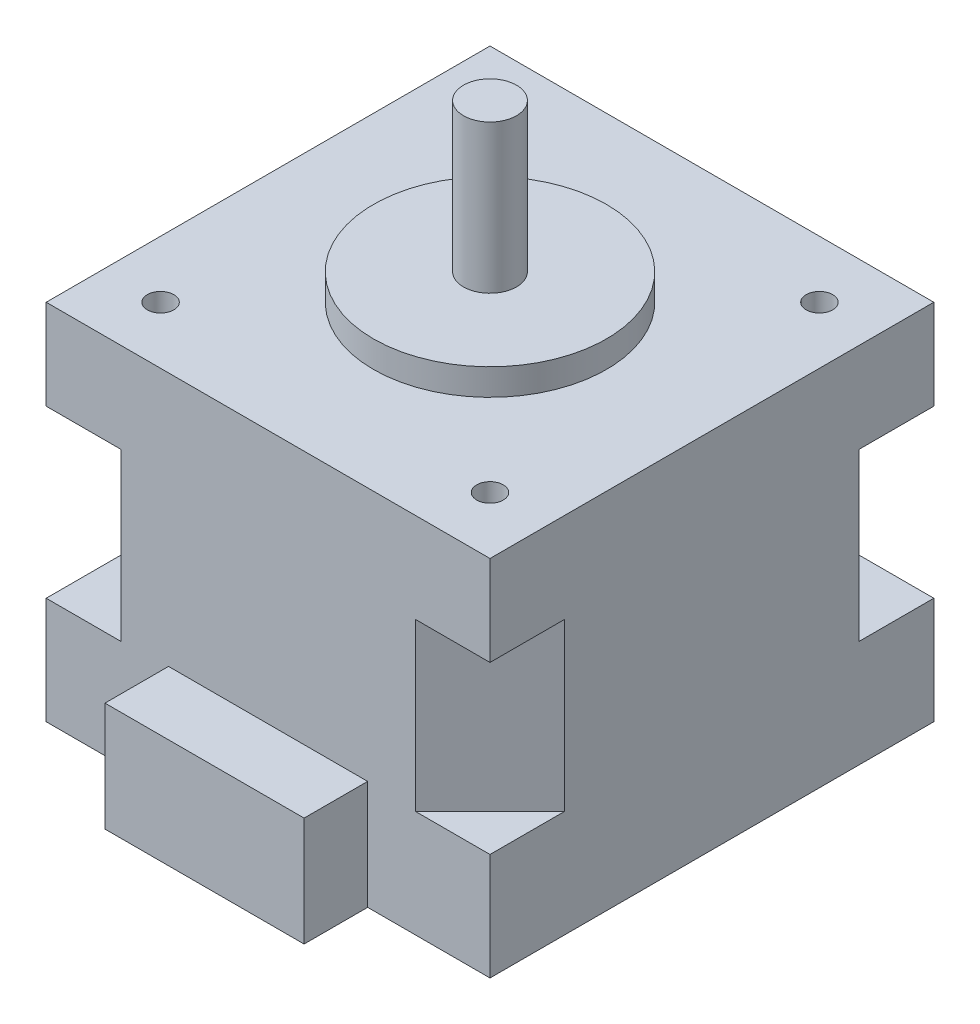
from build123d import *

# Parameters (mm, degrees)
SKETCH1_W               = 41.9
SKETCH1_H               = 41.9
BOSS_EXTRUDE1_DEPTH     = 34.3
SKETCH2_R               = 11
BOSS_EXTRUDE2_DEPTH     = 2.5
SKETCH3_R               = 2.5
BOSS_EXTRUDE3_DEPTH     = 14
SKETCH4_R               = 1.25
CUT_EXTRUDE1_DEPTH      = 7.9
MIRROR2_COPY_1_SKETCH_R = 1.25
MIRROR2_COPY_1_DEPTH    = 7.9
CUT_EXTRUDE2_DEPTH      = 15.7
MIRROR4_COPY_1_DEPTH    = 15.7
BOSS_EXTRUDE4_DEPTH     = 10.3
SKETCH12_R              = 4
CUT_EXTRUDE3_DEPTH      = 3


with BuildPart() as part:
    # Sketch1 → Boss-Extrude1 (new body)
    with BuildSketch(Plane(origin=(0, 0, 0), x_dir=(1, 0, 0), z_dir=(0, 1, 0))):
        Rectangle(SKETCH1_W, SKETCH1_H)
    extrude(amount=BOSS_EXTRUDE1_DEPTH)

    # Sketch2 → Boss-Extrude2 (add)
    with BuildSketch(Plane(origin=(0, 34.3, 0), x_dir=(1, 0, 0), z_dir=(0, 1, 0))):
        Circle(SKETCH2_R)
    extrude(amount=BOSS_EXTRUDE2_DEPTH)

    # Sketch3 → Boss-Extrude3 (add)
    with BuildSketch(Plane(origin=(0, 36.8, 0), x_dir=(1, 0, 0), z_dir=(0, 1, 0))):
        Circle(SKETCH3_R)
    extrude(amount=BOSS_EXTRUDE3_DEPTH)

    # Sketch4 → Cut-Extrude1 (cut)
    with BuildSketch(Plane(origin=(0, 34.3, 0), x_dir=(1, 0, 0), z_dir=(0, 1, 0))):
        with Locations((15.55, 15.55)):
            Circle(SKETCH4_R)
    cut_extrude1 = extrude(amount=-CUT_EXTRUDE1_DEPTH, mode=Mode.SUBTRACT)

    # Mirror1: Cut-Extrude1 across plane
    add(cut_extrude1.mirror(Plane(origin=(0, 0, 0), x_dir=(0, 0, 1), z_dir=(1, 0, 0))), mode=Mode.SUBTRACT)

    # Mirror2: Cut-Extrude1 across plane
    add(cut_extrude1.mirror(Plane.XY), mode=Mode.SUBTRACT)

    # Mirror2 copy 1 sketch → Mirror2 copy 1 (cut)
    with BuildSketch(Plane(origin=(0, 34.3, 0), x_dir=(-1, 0, 0), z_dir=(0, 1, 0))):
        with Locations((15.55, 15.55)):
            Circle(MIRROR2_COPY_1_SKETCH_R)
    extrude(amount=-MIRROR2_COPY_1_DEPTH, mode=Mode.SUBTRACT)

    # Sketch10 → Cut-Extrude2 (cut)
    with BuildSketch(Plane(origin=(0, 25.8, 0), x_dir=(-1, 0, 0), z_dir=(0, -1, 0))):
        Polygon((-20.95, 13.9), (-13.9, 20.95), (-20.95, 20.95), align=None)
    cut_extrude2 = extrude(amount=CUT_EXTRUDE2_DEPTH, mode=Mode.SUBTRACT)

    # Mirror3: Cut-Extrude2 across plane
    add(cut_extrude2.mirror(Plane(origin=(0, 0, 0), x_dir=(0, 0, 1), z_dir=(1, 0, 0))), mode=Mode.SUBTRACT)

    # Mirror4: Cut-Extrude2 across plane
    add(cut_extrude2.mirror(Plane.XY), mode=Mode.SUBTRACT)

    # Mirror4 copy 1 sketch → Mirror4 copy 1 (cut)
    with BuildSketch(Plane.XZ.offset(-25.8)):
        Polygon((-20.95, 13.9), (-13.9, 20.95), (-20.95, 20.95), align=None)
    extrude(amount=MIRROR4_COPY_1_DEPTH, mode=Mode.SUBTRACT)

    # Sketch11 → Boss-Extrude4 (add)
    with BuildSketch(Plane.XZ):
        Polygon((0, 20.95), (9.4, 20.95), (9.4, 26.95), (-9.4, 26.95), (-9.4, 20.95), align=None)
    extrude(amount=-BOSS_EXTRUDE4_DEPTH)

    # Sketch12 → Cut-Extrude3 (cut)
    with BuildSketch(Plane.XZ):
        Circle(SKETCH12_R)
    extrude(amount=-CUT_EXTRUDE3_DEPTH, mode=Mode.SUBTRACT)


solid = part.part
